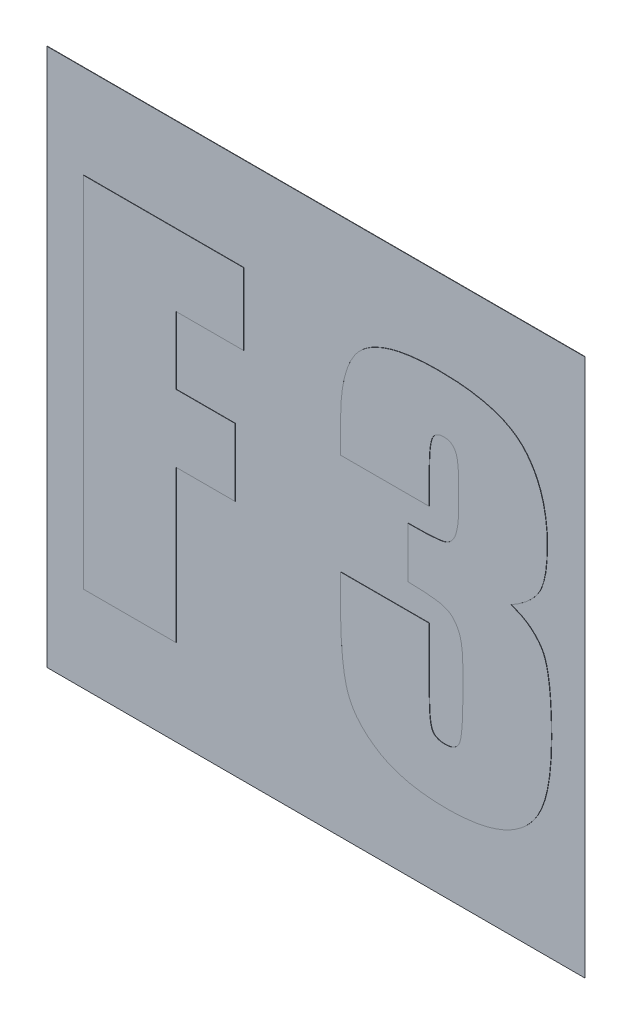
from build123d import *

# Parameters (mm, degrees)
SKETCH1_W           = 15
SKETCH1_H           = 15
BASE_EXTRUDE_DEPTH  = 0.01
BOSS_EXTRUDE1_DEPTH = 0.01


with BuildPart() as part:
    # Sketch1 → Base-Extrude (new body)
    with BuildSketch(Plane.XY):
        Rectangle(SKETCH1_W, SKETCH1_H)
    extrude(amount=BASE_EXTRUDE_DEPTH)

    # Sketch3 → Boss-Extrude1 (add)
    with BuildSketch(Plane.XY.offset(0.01)):
        Polygon((-6.472368832, 4.904808961), (-2.004055241, 4.904808961), (-2.004055241, 2.905826565), (-3.885450437, 2.905826565), (-3.885450437, 1.024431369), (-2.239229641, 1.024431369), (-2.239229641, -0.856963827), (-3.885450437, -0.856963827), (-3.885450437, -5.090103018), (-6.472368832, -5.090103018), align=None)
        with BuildLine():
            add(Edge.make_bspline(
                [(5.451708144, 0.49528897), (5.541704888, 0.46122907), (5.71609099, 0.395231423), (5.951267823, 0.254576822), (6.147281493, 0.079818861), (6.285825692, -0.092074441), (6.374221532, -0.261448951), (6.429491004, -0.425746475), (6.47634556, -0.625108119), (6.513333341, -0.861085485), (6.54456131, -1.13319291), (6.565545199, -1.441559516), (6.578417743, -1.785912523), (6.579330792, -2.027310906), (6.579810341, -2.154097624)],
                knots=[0, 0, 0, 0, 0.000288316, 0.000558667, 0.000816374, 0.001072913, 0.001215904, 0.001387325, 0.001591423, 0.001829741, 0.00210345, 0.002412902, 0.002756718, 0.003137057, 0.003137057, 0.003137057, 0.003137057], degree=3))
            add(Edge.make_bspline(
                [(6.579810341, -2.154097624), (6.579251611, -2.249649366), (6.578162254, -2.43594664), (6.565520748, -2.706880939), (6.542845162, -2.961695301), (6.514955923, -3.199828398), (6.475365682, -3.421508825), (6.4310113, -3.62688384), (6.375382308, -3.815865386), (6.311376041, -3.989219646), (6.237022264, -4.149908829), (6.151069105, -4.299319941), (6.050020595, -4.437378887), (5.940700172, -4.568709379), (5.816810406, -4.688656507), (5.679099503, -4.797101345), (5.531093612, -4.8981779), (5.370194177, -4.988868629), (5.196816475, -5.066913302), (5.012561471, -5.137635874), (4.815842154, -5.195751498), (4.60781307, -5.243417124), (4.388177835, -5.280292834), (4.156835455, -5.304852901), (3.913544341, -5.322479956), (3.747340028, -5.324329647), (3.662177947, -5.325277418)],
                knots=[0, 0, 0, 0, 0.000286642, 0.000558867, 0.000813371, 0.001054022, 0.001277849, 0.00148869, 0.001684033, 0.001868322, 0.002042585, 0.002214645, 0.002384444, 0.002555234, 0.002726743, 0.002900628, 0.003080515, 0.003263969, 0.003453887, 0.003650436, 0.00385563, 0.00406867, 0.004290375, 0.004523299, 0.004766386, 0.00502183, 0.00502183, 0.00502183, 0.00502183], degree=3))
            add(Edge.make_bspline(
                [(3.662177947, -5.325277418), (3.565978307, -5.324651197), (3.37886012, -5.323433134), (3.106134323, -5.30155964), (2.848949154, -5.271730523), (2.607716343, -5.227741017), (2.382277001, -5.171023718), (2.17313853, -5.100991344), (1.978289759, -5.021364866), (1.801922322, -4.924582203), (1.641206044, -4.819500382), (1.492410404, -4.711536803), (1.360037195, -4.595479188), (1.242042252, -4.47335357), (1.136273155, -4.347507072), (1.048139978, -4.21345763), (0.971968934, -4.075729036), (0.909481566, -3.928047215), (0.860011794, -3.763274966), (0.816012679, -3.57560507), (0.780160436, -3.360743847), (0.751608695, -3.119093652), (0.727605231, -2.851386475), (0.711525112, -2.556637663), (0.702857292, -2.23499193), (0.701274259, -2.011405899), (0.700450353, -1.895038325)],
                knots=[0, 0, 0, 0, 0.000288509, 0.000561179, 0.000820291, 0.001064983, 0.001296256, 0.001517038, 0.001726208, 0.001926803, 0.002119439, 0.002302072, 0.002477849, 0.002646761, 0.002811197, 0.002970184, 0.003127228, 0.003282835, 0.003450201, 0.003642724, 0.003860806, 0.004103281, 0.004372588, 0.00466702, 0.004988679, 0.005337785, 0.005337785, 0.005337785, 0.005337785], degree=3))
            Line((0.700450353, -1.895038325), (0.700450353, -1.092138227))
            Line((0.700450353, -1.092138227), (3.169781548, -1.092138227))
            Line((3.169781548, -1.092138227), (3.169781548, -2.765918523))
            add(Edge.make_bspline(
                [(3.169781548, -2.765918523), (3.17021198, -2.8192041), (3.171028418, -2.920275499), (3.175006718, -3.064808886), (3.179443639, -3.194167412), (3.189151196, -3.308058537), (3.199429809, -3.406909766), (3.213835296, -3.49033521), (3.230278504, -3.559125937), (3.252702283, -3.629681509), (3.299526285, -3.699935045), (3.383122461, -3.757103347), (3.489245053, -3.792340524), (3.568162966, -3.79513591), (3.610733547, -3.796643821)],
                knots=[0, 0, 0, 0, 0.000159856, 0.000303212, 0.000433777, 0.000548059, 0.000646058, 0.000731843, 0.000801805, 0.000858165, 0.000953457, 0.001048288, 0.001156937, 0.001284189, 0.001284189, 0.001284189, 0.001284189], degree=3))
            add(Edge.make_bspline(
                [(3.610733547, -3.796643821), (3.657620063, -3.794138108), (3.745079031, -3.789464118), (3.864542915, -3.747227033), (3.956695696, -3.672591069), (4.011087258, -3.586195046), (4.037803626, -3.496164203), (4.058275718, -3.405442093), (4.073156686, -3.291597084), (4.088363969, -3.155701403), (4.098765536, -2.996924463), (4.105963633, -2.815589336), (4.109019718, -2.611594501), (4.109976338, -2.468276058), (4.110479146, -2.392946624)],
                knots=[0, 0, 0, 0, 0.000140406, 0.000261904, 0.000372951, 0.000490193, 0.000561659, 0.000653927, 0.000769034, 0.000905786, 0.001064178, 0.001246219, 0.001450193, 0.001676188, 0.001676188, 0.001676188, 0.001676188], degree=3))
            Line((4.110479146, -2.392946624), (4.110479146, -1.691098025))
            add(Edge.make_bspline(
                [(4.110479146, -1.691098025), (4.109713746, -1.600362341), (4.108287812, -1.431322569), (4.08194848, -1.197917545), (4.044954905, -1.001849323), (3.985393347, -0.843187957), (3.909844021, -0.715148139), (3.819006664, -0.611594312), (3.710227787, -0.532893563), (3.6058627, -0.487905925), (3.510331925, -0.461725122), (3.422645179, -0.443464033), (3.319407062, -0.429706846), (3.201185368, -0.416713215), (3.067602219, -0.406017567), (2.918750523, -0.397065261), (2.755237446, -0.389185698), (2.641261806, -0.38749592), (2.581845549, -0.386615028)],
                knots=[0, 0, 0, 0, 0.00027202, 0.00050677, 0.000703876, 0.000869029, 0.001012397, 0.001147735, 0.001279304, 0.001411755, 0.001486206, 0.00157629, 0.001680223, 0.001798512, 0.001933087, 0.002082191, 0.002245876, 0.002424132, 0.002424132, 0.002424132, 0.002424132], degree=3))
            Line((2.581845549, -0.386615028), (2.581845549, 1.024431369))
            add(Edge.make_bspline(
                [(2.581845549, 1.024431369), (2.648600291, 1.025108849), (2.775373656, 1.026395444), (2.955465308, 1.02722335), (3.115410238, 1.032245699), (3.25494493, 1.042357761), (3.374484854, 1.05083456), (3.474597157, 1.061117544), (3.554479878, 1.075150689), (3.633822017, 1.096367081), (3.714735309, 1.136821769), (3.794334463, 1.206455107), (3.86083388, 1.295680521), (3.910135048, 1.408923566), (3.948380873, 1.548008373), (3.974310757, 1.718115255), (3.99035213, 1.920723759), (3.992004522, 2.066756753), (3.992891946, 2.145184367)],
                knots=[0, 0, 0, 0, 0.000200274, 0.000380339, 0.000540279, 0.000680216, 0.000799993, 0.000899818, 0.000981984, 0.001043059, 0.001145767, 0.001249992, 0.001357659, 0.001476871, 0.0016182, 0.001789464, 0.001992242, 0.002227481, 0.002227481, 0.002227481, 0.002227481], degree=3))
            Line((3.992891946, 2.145184367), (3.992891946, 2.722096566))
            add(Edge.make_bspline(
                [(3.992891946, 2.722096566), (3.992156958, 2.80480146), (3.990815348, 2.955766705), (3.974157766, 3.158867539), (3.944994071, 3.316687903), (3.902403692, 3.434210749), (3.840573884, 3.515071041), (3.769250527, 3.573837218), (3.680406937, 3.605166698), (3.617687502, 3.609231859), (3.585011347, 3.611349764)],
                knots=[0, 0, 0, 0, 0.000248097, 0.000452863, 0.000610325, 0.000729055, 0.000823493, 0.000912446, 0.001002548, 0.001100547, 0.001100547, 0.001100547, 0.001100547], degree=3))
            add(Edge.make_bspline(
                [(3.585011347, 3.611349764), (3.547813053, 3.610036204), (3.477965928, 3.607569737), (3.383466793, 3.567715617), (3.306078747, 3.507667601), (3.261348874, 3.435575677), (3.235519365, 3.364853788), (3.21734241, 3.297266999), (3.203718057, 3.215962863), (3.190130712, 3.121726109), (3.182222609, 3.013679986), (3.174137767, 2.892462124), (3.171289987, 2.757627757), (3.17030143, 2.663301825), (3.169781548, 2.613695866)],
                knots=[0, 0, 0, 0, 0.000110788, 0.000208026, 0.000302142, 0.000400502, 0.000457487, 0.000527907, 0.000610073, 0.000704654, 0.000813443, 0.000934928, 0.001069101, 0.001217933, 0.001217933, 0.001217933, 0.001217933], degree=3))
            Line((3.169781548, 2.613695866), (3.169781548, 1.729954568))
            Line((3.169781548, 1.729954568), (0.700450353, 1.729954568))
            Line((0.700450353, 1.729954568), (0.700450353, 2.613695866))
            add(Edge.make_bspline(
                [(0.700450353, 2.613695866), (0.702730934, 2.732564889), (0.707099736, 2.960276734), (0.735480875, 3.287167866), (0.786008768, 3.583612256), (0.857824167, 3.849811851), (0.946305898, 4.087948018), (1.059181309, 4.295504083), (1.191255618, 4.474908935), (1.348525371, 4.622731781), (1.526270005, 4.747928152), (1.728535846, 4.85095263), (1.951963354, 4.9418512), (2.20006964, 5.014787074), (2.47175811, 5.07095155), (2.767736781, 5.110214139), (3.086606239, 5.13714693), (3.30751876, 5.139018027), (3.421491648, 5.139983361)],
                knots=[0, 0, 0, 0, 0.000356607, 0.000683135, 0.00098338, 0.001257483, 0.0015093, 0.001743619, 0.001964095, 0.002174624, 0.00238821, 0.002614205, 0.002854056, 0.003110989, 0.00338881, 0.003685544, 0.004006267, 0.004348084, 0.004348084, 0.004348084, 0.004348084], degree=3))
            add(Edge.make_bspline(
                [(3.421491648, 5.139983361), (3.563633857, 5.137990237), (3.836088406, 5.134169869), (4.227351116, 5.10199337), (4.582669765, 5.044753192), (4.904044762, 4.970086889), (5.188966131, 4.869258179), (5.438231113, 4.746072414), (5.652827918, 4.600640957), (5.831971731, 4.430106467), (5.980716849, 4.239615452), (6.110987367, 4.034438308), (6.218830297, 3.810094157), (6.309654456, 3.569479907), (6.376396325, 3.310417121), (6.425663584, 3.035308665), (6.45834142, 2.742475657), (6.460905417, 2.540907636), (6.462223141, 2.437315066)],
                knots=[0, 0, 0, 0, 0.000426396, 0.000817305, 0.001176449, 0.001505321, 0.001805768, 0.002081026, 0.002337368, 0.002580399, 0.002819707, 0.003060813, 0.003308147, 0.003565119, 0.003831173, 0.004109389, 0.004403185, 0.004713824, 0.004713824, 0.004713824, 0.004713824], degree=3))
            add(Edge.make_bspline(
                [(6.462223141, 2.437315066), (6.461622613, 2.368090193), (6.46046325, 2.234446478), (6.448688471, 2.04145572), (6.43314227, 1.863552201), (6.409776505, 1.700127517), (6.376800405, 1.552361275), (6.337572556, 1.418832167), (6.295732098, 1.298595255), (6.22169852, 1.159141118), (6.106697718, 0.995839339), (5.92607923, 0.81879231), (5.707966569, 0.645416236), (5.540092831, 0.547068542), (5.451708144, 0.49528897)],
                knots=[0, 0, 0, 0, 0.000207647, 0.000400879, 0.000579862, 0.000743299, 0.000895751, 0.001033548, 0.001160854, 0.00127672, 0.00150611, 0.001756853, 0.002032895, 0.002339828, 0.002339828, 0.002339828, 0.002339828], degree=3))
        make_face()
    extrude(amount=BOSS_EXTRUDE1_DEPTH)


solid = part.part
